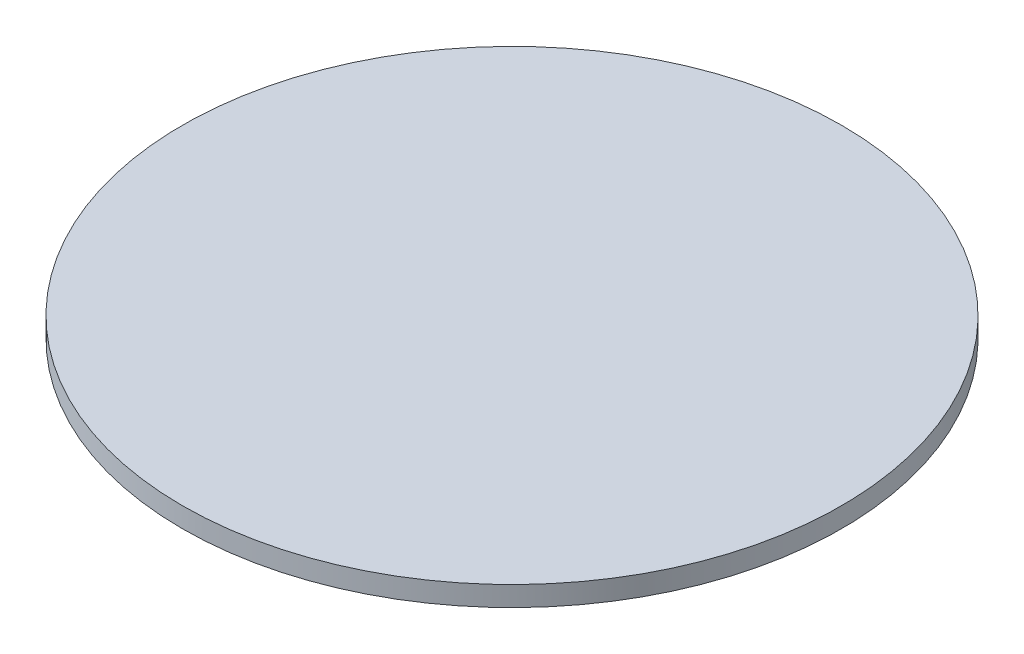
from build123d import *

# Parameters (mm, degrees)
SKETCH1_R           = 16.5
BOSS_EXTRUDE1_DEPTH = 1


with BuildPart() as part:
    # Sketch1 → Boss-Extrude1 (new body)
    with BuildSketch(Plane(origin=(0, 0, 0), x_dir=(1, 0, 0), z_dir=(0, 1, 0))):
        Circle(SKETCH1_R)
    extrude(amount=BOSS_EXTRUDE1_DEPTH)


solid = part.part
